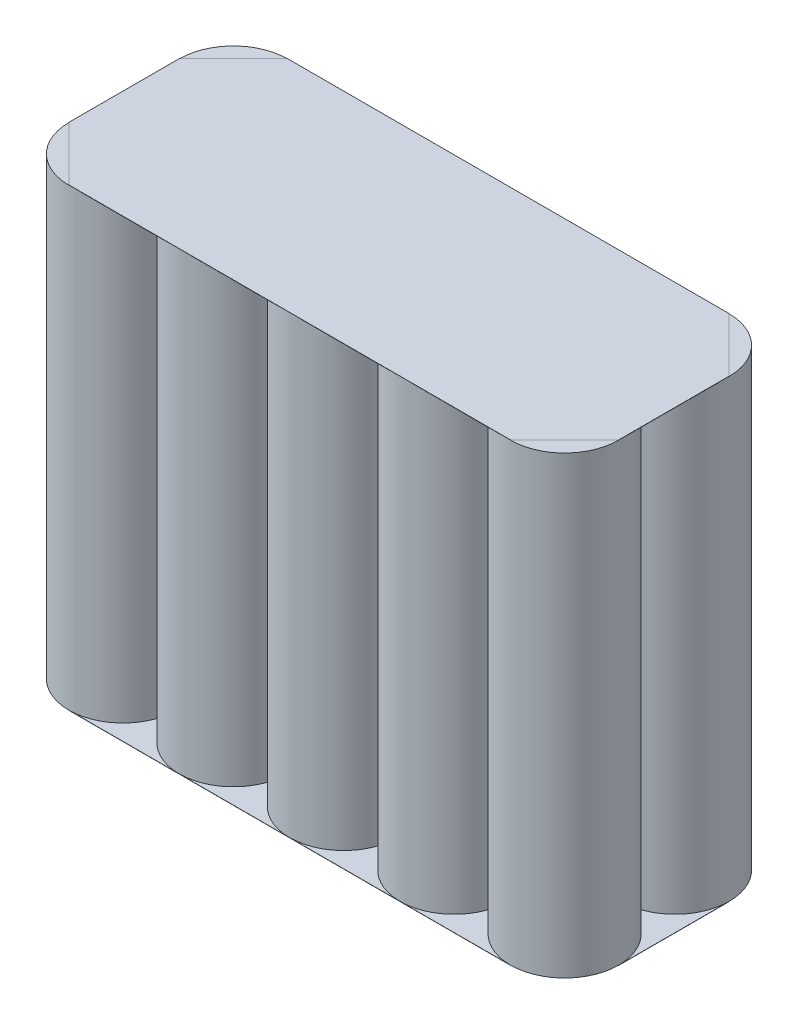
from build123d import *

# Parameters (mm, degrees)
SKETCH1_R              = 6.35
BOSS_EXTRUDE1_DEPTH    = 50.8
SKETCH1_R_2            = 6.349999999999999
BOSS_EXTRUDE1_2_DEPTH  = 50.8
SKETCH1_R_3            = 6.350000000000002
BOSS_EXTRUDE1_3_DEPTH  = 50.8
BOSS_EXTRUDE1_4_DEPTH  = 50.8
BOSS_EXTRUDE1_5_DEPTH  = 50.8
BOSS_EXTRUDE1_6_DEPTH  = 50.8
BOSS_EXTRUDE1_7_DEPTH  = 50.8
SKETCH1_R_4            = 6.350000000000003
BOSS_EXTRUDE1_8_DEPTH  = 50.8
BOSS_EXTRUDE1_9_DEPTH  = 50.8
SKETCH1_R_5            = 6.3500000000000005
BOSS_EXTRUDE1_10_DEPTH = 50.8
BOSS_EXTRUDE2_DEPTH    = 1.27
BOSS_EXTRUDE3_DEPTH    = 0.0254


with BuildPart() as part:
    # Sketch1 → Boss-Extrude1 (new body)
    with BuildSketch(Plane(origin=(0, 0, 0), x_dir=(1, 0, 0), z_dir=(0, 1, 0))):
        with Locations(Location((0, 0, 0), (0, 0, 270))):
            Circle(SKETCH1_R)
    extrude(amount=BOSS_EXTRUDE1_DEPTH)



with BuildPart() as body_2:
    # Sketch1 → Boss-Extrude1 2 (new body)
    with BuildSketch(Plane(origin=(0, 0, 0), x_dir=(1, 0, 0), z_dir=(0, 1, 0))):
        with Locations(Location((12.954, 0, 0), (0, 0, 270))):
            Circle(SKETCH1_R_2)
    extrude(amount=BOSS_EXTRUDE1_2_DEPTH)


with BuildPart() as body_3:
    # Sketch1 → Boss-Extrude1 3 (new body)
    with BuildSketch(Plane(origin=(0, 0, 0), x_dir=(1, 0, 0), z_dir=(0, 1, 0))):
        with Locations(Location((25.908, 0, 0), (0, 0, 270))):
            Circle(SKETCH1_R_3)
    extrude(amount=BOSS_EXTRUDE1_3_DEPTH)


with BuildPart() as body_4:
    # Sketch1 → Boss-Extrude1 4 (new body)
    with BuildSketch(Plane(origin=(0, 0, 0), x_dir=(1, 0, 0), z_dir=(0, 1, 0))):
        with Locations(Location((38.862, 0, 0), (0, 0, 270))):
            Circle(SKETCH1_R_3)
    extrude(amount=BOSS_EXTRUDE1_4_DEPTH)


with BuildPart() as body_5:
    # Sketch1 → Boss-Extrude1 5 (new body)
    with BuildSketch(Plane(origin=(0, 0, 0), x_dir=(1, 0, 0), z_dir=(0, 1, 0))):
        with Locations(Location((51.816, 0, 0), (0, 0, 270))):
            Circle(SKETCH1_R_3)
    extrude(amount=BOSS_EXTRUDE1_5_DEPTH)


with BuildPart() as body_6:
    # Sketch1 → Boss-Extrude1 6 (new body)
    with BuildSketch(Plane(origin=(0, 0, 0), x_dir=(1, 0, 0), z_dir=(0, 1, 0))):
        with Locations(Location((12.954000000000136, -12.954, 0), (0, 0, 270))):
            Circle(SKETCH1_R)
    extrude(amount=BOSS_EXTRUDE1_6_DEPTH)


with BuildPart() as body_7:
    # Sketch1 → Boss-Extrude1 7 (new body)
    with BuildSketch(Plane(origin=(0, 0, 0), x_dir=(1, 0, 0), z_dir=(0, 1, 0))):
        with Locations(Location((25.908000000000136, -12.954, 0), (0, 0, 270))):
            Circle(SKETCH1_R)
    extrude(amount=BOSS_EXTRUDE1_7_DEPTH)


with BuildPart() as body_8:
    # Sketch1 → Boss-Extrude1 8 (new body)
    with BuildSketch(Plane(origin=(0, 0, 0), x_dir=(1, 0, 0), z_dir=(0, 1, 0))):
        with Locations(Location((38.86200000000014, -12.954, 0), (0, 0, 270))):
            Circle(SKETCH1_R_4)
    extrude(amount=BOSS_EXTRUDE1_8_DEPTH)


with BuildPart() as body_9:
    # Sketch1 → Boss-Extrude1 9 (new body)
    with BuildSketch(Plane(origin=(0, 0, 0), x_dir=(1, 0, 0), z_dir=(0, 1, 0))):
        with Locations(Location((51.81600000000014, -12.954, 0), (0, 0, 270))):
            Circle(SKETCH1_R_4)
    extrude(amount=BOSS_EXTRUDE1_9_DEPTH)


with BuildPart() as body_10:
    # Sketch1 → Boss-Extrude1 10 (new body)
    with BuildSketch(Plane(origin=(0, 0, 0), x_dir=(1, 0, 0), z_dir=(0, 1, 0))):
        with Locations(Location((1.3569e-13, -12.954, 0), (0, 0, 270))):
            Circle(SKETCH1_R_5)
    extrude(amount=BOSS_EXTRUDE1_10_DEPTH)


with BuildPart() as part_1:
    add(part.part)

    add(body_2.part)  # Boss-Extrude2 merges body 2

    add(body_3.part)  # Boss-Extrude2 merges body 3

    add(body_4.part)  # Boss-Extrude2 merges body 4

    add(body_5.part)  # Boss-Extrude2 merges body 5

    add(body_6.part)  # Boss-Extrude2 merges body 6

    add(body_7.part)  # Boss-Extrude2 merges body 7

    add(body_8.part)  # Boss-Extrude2 merges body 8

    add(body_9.part)  # Boss-Extrude2 merges body 9

    add(body_10.part)  # Boss-Extrude2 merges body 10
    # Sketch4 → Boss-Extrude2 (add)
    with BuildSketch(Plane(origin=(0, 50.8, 0), x_dir=(1, 0, 0), z_dir=(0, 1, 0))):
        with BuildLine():
            Line((1.3569e-13, -6.604), (0, -6.35))
            ThreePointArc((0, -6.35), (-4.490128060534576, 4.490128060534577), (6.35, 0))
            Line((6.35, 0), (6.603999999999998, 0))
            ThreePointArc((6.603999999999998, 0), (12.954, 6.350000000000001), (19.304000000000002, 0))
            Line((19.304000000000002, 0), (19.558, 0))
            ThreePointArc((19.558, 0), (25.908, 6.350000000000001), (32.258, 0))
            Line((32.258, 0), (32.512, 0))
            ThreePointArc((32.512, 0), (38.862, 6.350000000000001), (45.212, 0))
            Line((45.212, 0), (45.466, 0))
            ThreePointArc((45.466, 0), (56.30612806053458, 4.490128060534578), (51.816, -6.350000000000002))
            Line((51.816, -6.350000000000002), (51.81600000000014, -6.603999999999998))
            ThreePointArc((51.81600000000014, -6.603999999999998), (56.30612806053472, -17.44412806053458), (45.466000000000136, -12.954))
            Line((45.466000000000136, -12.954), (45.21200000000014, -12.954))
            ThreePointArc((45.21200000000014, -12.954), (38.86200000000014, -19.304000000000002), (32.512000000000135, -12.954))
            Line((32.512000000000135, -12.954), (32.25800000000013, -12.954))
            ThreePointArc((32.25800000000013, -12.954), (25.908000000000136, -19.304), (19.55800000000014, -12.954))
            Line((19.55800000000014, -12.954), (19.304000000000133, -12.954))
            ThreePointArc((19.304000000000133, -12.954), (12.954000000000134, -19.304), (6.604000000000137, -12.954))
            Line((6.604000000000137, -12.954), (6.350000000000135, -12.954))
            ThreePointArc((6.350000000000135, -12.954), (-4.490128060534443, -17.444128060534577), (1.3569e-13, -6.604))
        make_face()
    boss_extrude2 = extrude(amount=BOSS_EXTRUDE2_DEPTH)

    # Mirror1: Boss-Extrude2 across plane
    add(boss_extrude2.mirror(Plane.ZX.offset(25.4)))

    # Sketch5 → Boss-Extrude3 (add)
    with BuildSketch(Plane(origin=(0, 52.07, 0), x_dir=(1, 0, 0), z_dir=(0, 1, 0))):
        Polygon((51.81599999999998, 6.350000000000001), (-2.602e-14, 6.349999999999999), (-6.35, -4.434e-14), (-6.349999999999865, -12.954000000000045), (2.5457e-13, -19.304000000000002), (51.81600000000021, -19.304000000000002), (58.16600000000014, -12.95399999999983), (58.166000000000004, 0), align=None)
    boss_extrude3 = extrude(amount=BOSS_EXTRUDE3_DEPTH)

    # Mirror2: Boss-Extrude3 across plane
    add(boss_extrude3.mirror(Plane.ZX.offset(25.4)))


solid = part_1.part
